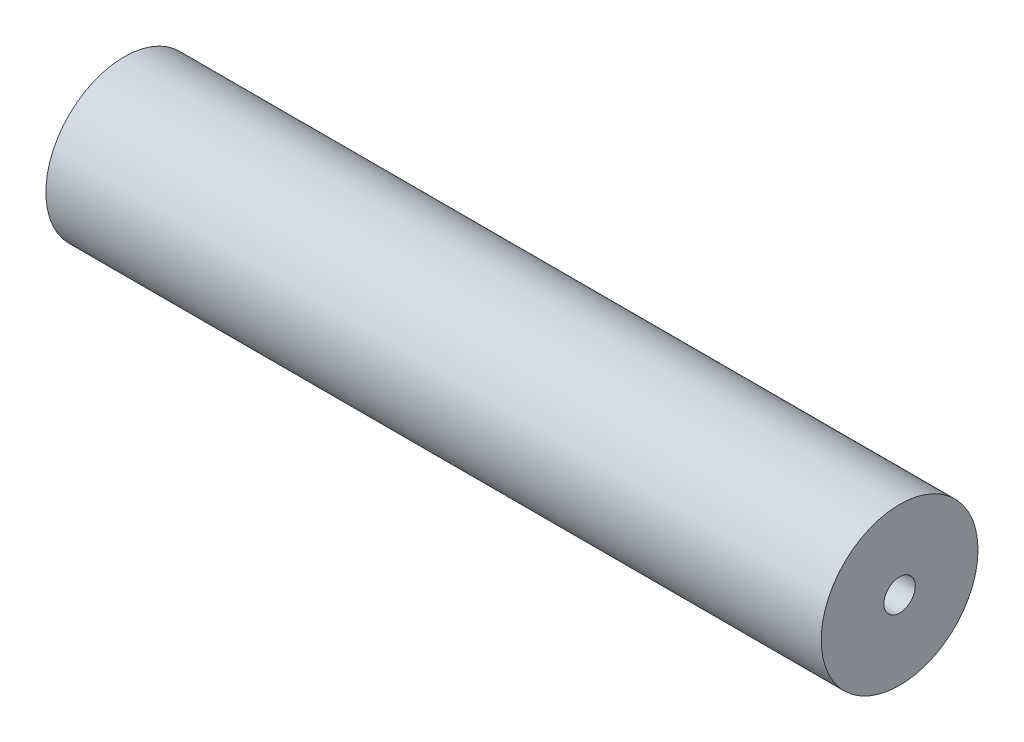
from build123d import *


with BuildPart() as part:
    # Sketch1 → Revolve1 (revolve)
    with BuildSketch(Plane.XY):
        Polygon((0, 7.9375), (78.5, 7.9375), (78.5, 1.5875), (68.5, 1.5875), (68.5, 0), (10, 0), (10, 1.5875), (0, 1.5875), align=None)
    revolve(axis=Axis((0, 0, 0), (-1, 0, 0)))


solid = part.part
